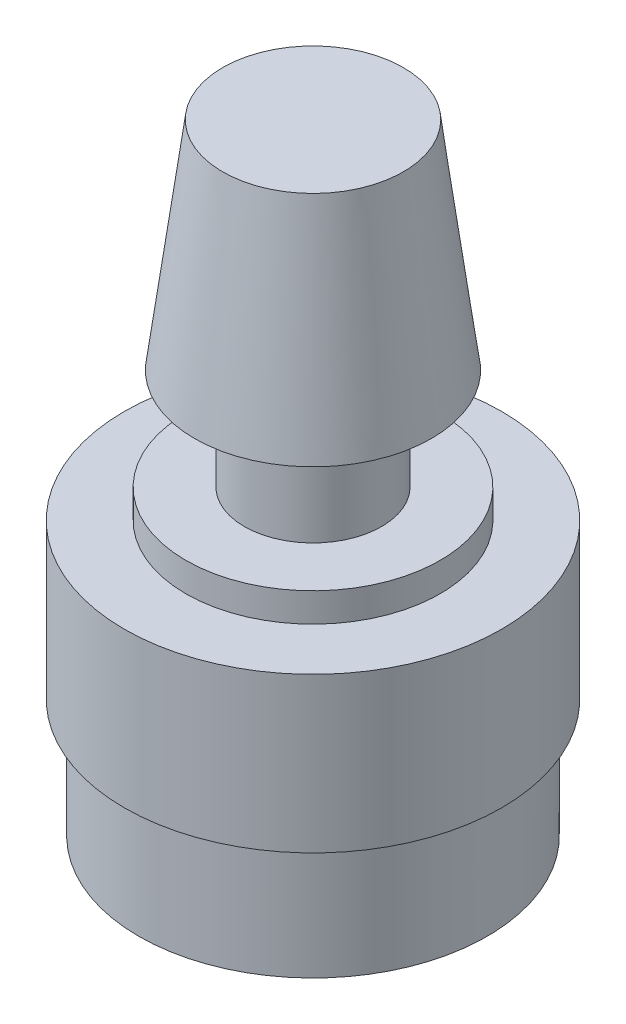
from build123d import *

# Parameters (mm, degrees)
ESQUISSE1_R        = 13.05
BOSS_EXTRU_1_DEPTH = 10.7
ESQUISSE2_R        = 8.8
BOSS_EXTRU_2_DEPTH = 2
ESQUISSE3_R        = 4.75
BOSS_EXTRU_3_DEPTH = 7
ESQUISSE5_R        = 12.05
ESQUISSE5_R_2      = 11.05
BOSS_EXTRU_5_DEPTH = 8.2


with BuildPart() as part:
    # Esquisse1 → Boss.-Extru.1 (new body)
    with BuildSketch(Plane(origin=(0, 0, 0), x_dir=(1, 0, 0), z_dir=(0, 1, 0))):
        Circle(ESQUISSE1_R)
    extrude(amount=BOSS_EXTRU_1_DEPTH)

    # Esquisse2 → Boss.-Extru.2 (add)
    with BuildSketch(Plane(origin=(0, 10.7, 0), x_dir=(1, 0, 0), z_dir=(0, 1, 0))):
        Circle(ESQUISSE2_R)
    extrude(amount=BOSS_EXTRU_2_DEPTH)

    # Esquisse3 → Boss.-Extru.3 (add)
    with BuildSketch(Plane(origin=(0, 12.7, 0), x_dir=(1, 0, 0), z_dir=(0, 1, 0))):
        Circle(ESQUISSE3_R)
    extrude(amount=BOSS_EXTRU_3_DEPTH)

    # Esquisse5 → Boss.-Extru.5 (add)
    with BuildSketch(Plane.XZ):
        Circle(ESQUISSE5_R)
        Circle(ESQUISSE5_R_2, mode=Mode.SUBTRACT)
    extrude(amount=BOSS_EXTRU_5_DEPTH)

    # Esquisse6 → Révolution1 (revolve)
    with BuildSketch(Plane.XY):
        Polygon((0, 19.7), (8.2, 19.7), (6.25, 34.7), (0, 34.7), align=None)
    revolve(axis=Axis((0, 34.7, 0), (0, -1, 0)))


solid = part.part
